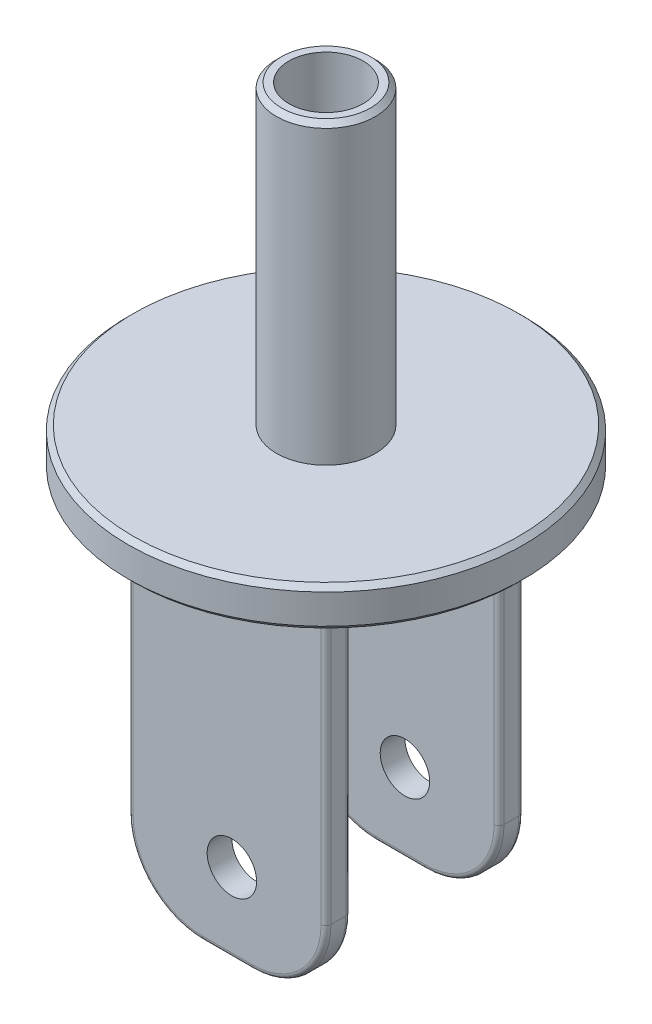
from build123d import *

# Parameters (mm, degrees)
SKETCH2_R             = 40
BOSS_EXTRUDE1_DEPTH   = 8
SKETCH3_W             = 40
SKETCH3_H             = 5
BOSS_EXTRUDE2_DEPTH   = 75
FILLET1_R             = 15
FILLET3_R             = 1
FILLET4_R             = 4
FILLET1_OF_MIRROR10_R = 15
FILLET3_OF_MIRROR10_R = 1
FILLET4_OF_MIRROR10_R = 4
SKETCH5_R             = 5
CUT_EXTRUDE1_DEPTH    = 40
SKETCH6_R             = 10
BOSS_EXTRUDE3_DEPTH   = 60
SKETCH7_R             = 7.5
CUT_EXTRUDE2_DEPTH    = 60
CHAMFER1_SIZE         = 1


with BuildPart() as part:
    # Sketch2 → Boss-Extrude1 (new body)
    with BuildSketch(Plane(origin=(0, 0, 0), x_dir=(1, 0, 0), z_dir=(0, 1, 0))):
        Circle(SKETCH2_R)
    extrude(amount=BOSS_EXTRUDE1_DEPTH)

    # Sketch3 → Boss-Extrude2 (add)
    with BuildSketch(Plane.XZ):
        with Locations((0, -17.5)):
            Rectangle(SKETCH3_W, SKETCH3_H)
    boss_extrude2 = extrude(amount=BOSS_EXTRUDE2_DEPTH)

    # Fillet1
    fillet1_edges = [part.edges().sort_by_distance(p)[0] for p in [
        (-20, -75, -17.5),
        (20, -75, -17.5),
    ]]
    fillet(fillet1_edges, radius=FILLET1_R)

    # Fillet3
    fillet3_edges = [part.edges().sort_by_distance(p)[0] for p in [
        (0, -75, -20),
        (0, -75, -15),
        (20, -30, -20),
        (-20, -30, -20),
        (15.606601718, -70.606601718, -20),
        (-15.606601718, -70.606601718, -20),
        (-20, -30, -15),
        (20, -30, -15),
        (15.606601718, -70.606601718, -15),
        (-15.606601718, -70.606601718, -15),
    ]]
    fillet(fillet3_edges, radius=FILLET3_R)

    # Fillet4
    fillet4_edges = [part.edges().sort_by_distance(p)[0] for p in [
        (-20, 0, -17.5),
        (0, 0, -15),
        (20, 0, -17.5),
        (0, 0, -20),
        (-19.707106781, 0, -15.292893219),
        (19.707106781, 0, -15.292893219),
        (19.707106781, 0, -19.707106781),
        (-19.707106781, 0, -19.707106781),
    ]]
    fillet(fillet4_edges, radius=FILLET4_R)

    # Mirror10: Boss-Extrude2 across plane
    add(boss_extrude2.mirror(Plane.XY))

    # Fillet1 of Mirror10
    fillet1_of_mirror10_edges = [part.edges().sort_by_distance(p)[0] for p in [
        (-20, -75, 17.5),
        (20, -75, 17.5),
    ]]
    fillet(fillet1_of_mirror10_edges, radius=FILLET1_OF_MIRROR10_R)

    # Fillet3 of Mirror10
    fillet3_of_mirror10_edges = [part.edges().sort_by_distance(p)[0] for p in [
        (0, -75, 20),
        (0, -75, 15),
        (20, -30, 20),
        (-20, -30, 20),
        (15.606601718, -70.606601718, 20),
        (-15.606601718, -70.606601718, 20),
        (-20, -30, 15),
        (20, -30, 15),
        (15.606601718, -70.606601718, 15),
        (-15.606601718, -70.606601718, 15),
    ]]
    fillet(fillet3_of_mirror10_edges, radius=FILLET3_OF_MIRROR10_R)

    # Fillet4 of Mirror10
    fillet4_of_mirror10_edges = [part.edges().sort_by_distance(p)[0] for p in [
        (-20, 0, 17.5),
        (0, 0, 15),
        (20, 0, 17.5),
        (0, 0, 20),
        (-19.707106781, 0, 15.292893219),
        (19.707106781, 0, 15.292893219),
        (19.707106781, 0, 19.707106781),
        (-19.707106781, 0, 19.707106781),
    ]]
    fillet(fillet4_of_mirror10_edges, radius=FILLET4_OF_MIRROR10_R)

    # Sketch5 → Cut-Extrude1 (cut)
    with BuildSketch(Plane(origin=(0, 0, -20), x_dir=(-1, 0, 0), z_dir=(0, 0, -1))):
        with Locations((-0.961594328, -59)):
            Circle(SKETCH5_R)
    extrude(amount=-CUT_EXTRUDE1_DEPTH, mode=Mode.SUBTRACT)

    # Sketch6 → Boss-Extrude3 (add)
    with BuildSketch(Plane(origin=(0, 8, 0), x_dir=(1, 0, 0), z_dir=(0, 1, 0))):
        Circle(SKETCH6_R)
    extrude(amount=BOSS_EXTRUDE3_DEPTH)

    # Sketch7 → Cut-Extrude2 (cut)
    with BuildSketch(Plane(origin=(0, 68, 0), x_dir=(1, 0, 0), z_dir=(0, 1, 0))):
        Circle(SKETCH7_R)
    extrude(amount=-CUT_EXTRUDE2_DEPTH, mode=Mode.SUBTRACT)

    # Chamfer1
    chamfer1_edges = [part.edges().sort_by_distance(p)[0] for p in [
        (-10, 68, 0),
        (-40, 0, 0),
        (-40, 8, 0),
    ]]
    chamfer(chamfer1_edges, length=CHAMFER1_SIZE)


solid = part.part
